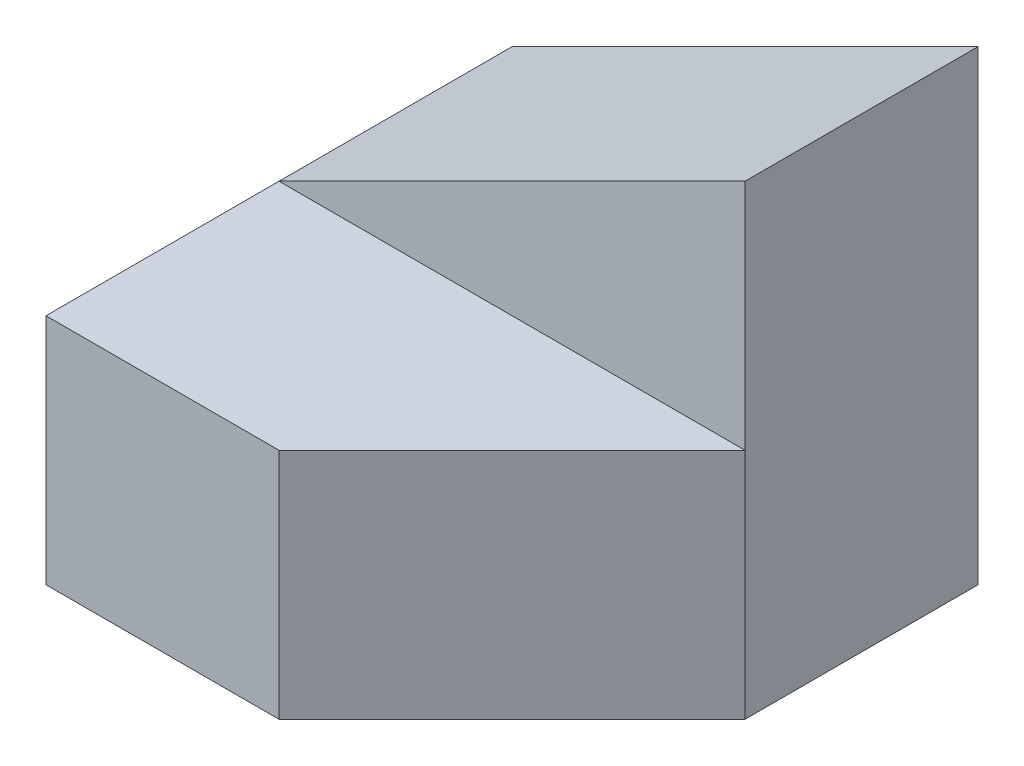
from build123d import *

# Parameters (mm, degrees)
SKETCH1_W           = 40
SKETCH1_H           = 40
BOSS_EXTRUDE1_DEPTH = 40
CUT_EXTRUDE1_DEPTH  = 40
SKETCH3_W           = 20
SKETCH3_H           = 20
CUT_EXTRUDE2_DEPTH  = 40
CUT_EXTRUDE3_DEPTH  = 40


with BuildPart() as part:
    # Sketch1 → Boss-Extrude1 (new body)
    with BuildSketch(Plane.XY):
        with Locations((20, 20)):
            Rectangle(SKETCH1_W, SKETCH1_H)
    extrude(amount=BOSS_EXTRUDE1_DEPTH)

    # Sketch2 → Cut-Extrude1 (cut)
    with BuildSketch(Plane.XY.offset(40)):
        Polygon((40, 40), (0, 20), (0, 40), align=None)
    extrude(amount=-CUT_EXTRUDE1_DEPTH, mode=Mode.SUBTRACT)

    # Sketch3 → Cut-Extrude2 (cut)
    with BuildSketch(Plane(origin=(40, 0, 0), x_dir=(0, 0, -1), z_dir=(1, 0, 0))):
        with Locations((-30, 30)):
            Rectangle(SKETCH3_W, SKETCH3_H)
    extrude(amount=-CUT_EXTRUDE2_DEPTH, mode=Mode.SUBTRACT)

    # Sketch4 → Cut-Extrude3 (cut)
    with BuildSketch(Plane(origin=(0, 20, 0), x_dir=(1, 0, 0), z_dir=(0, 1, 0))):
        Polygon((40, -20), (20, -40), (40, -40), align=None)
    extrude(amount=-CUT_EXTRUDE3_DEPTH, mode=Mode.SUBTRACT)


solid = part.part
